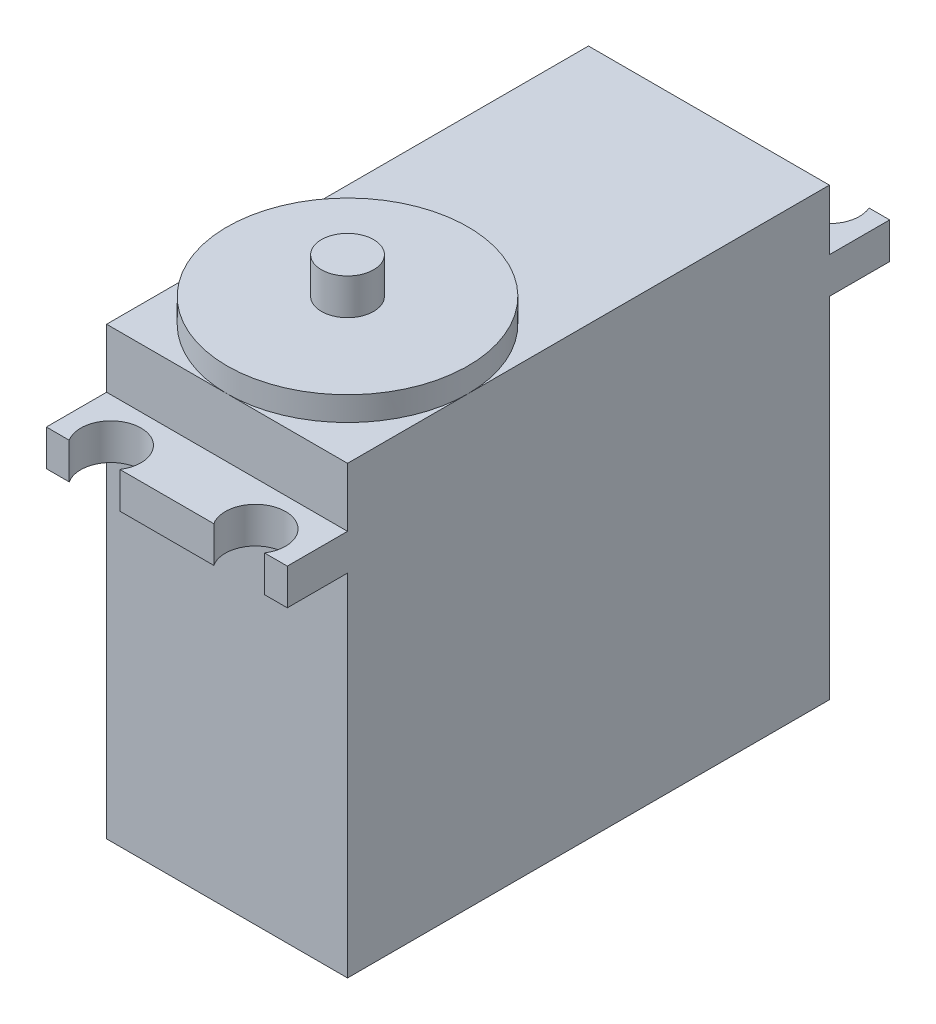
from build123d import *

# Parameters (mm, degrees)
SKETCH_1_W           = 20
SKETCH_1_H           = 40
EXTRUDE_1_DEPTH      = 37
SKETCH_2_R           = 0.75
CUT_EXTRUDE_10_DEPTH = 2
SKETCH_3_R           = 10
EXTRUDE_3_DEPTH      = 2
SKETCH_4_R           = 2.167388434
EXTRUDE_4_DEPTH      = 3
SKETCH_5_W           = 20
SKETCH_5_H           = 3
EXTRUDE_5_DEPTH      = 5
SKETCH_6_R           = 2.5
CUT_EXTRUDE_13_DEPTH = 3
SKETCH_9_W           = 20
SKETCH_9_H           = 3
EXTRUDE_7_DEPTH      = 5
SKETCH_10_R          = 2.5
CUT_EXTRUDE_14_DEPTH = 3


with BuildPart() as part:
    # 草图1 → 凸台-拉伸1 (new body)
    with BuildSketch(Plane(origin=(0, 0, 0), x_dir=(1, 0, 0), z_dir=(0, 1, 0))):
        Rectangle(SKETCH_1_W, SKETCH_1_H)
    extrude(amount=EXTRUDE_1_DEPTH)

    # 草图2 → 切除-拉伸10 (cut)
    with BuildSketch(Plane(origin=(0, 0, 0), x_dir=(1, 0, 0), z_dir=(0, 1, 0))):
        with Locations((-9, 19)):
            Circle(SKETCH_2_R)
        with Locations((9, 19)):
            Circle(SKETCH_2_R)
        with Locations((-9, -19)):
            Circle(SKETCH_2_R)
        with Locations((9, -19)):
            Circle(SKETCH_2_R)
    extrude(amount=CUT_EXTRUDE_10_DEPTH, mode=Mode.SUBTRACT)

    # 草图3 → 凸台-拉伸3 (add)
    with BuildSketch(Plane(origin=(0, 37, 0), x_dir=(1, 0, 0), z_dir=(0, 1, 0))):
        with Locations((0, -10)):
            Circle(SKETCH_3_R)
    extrude(amount=EXTRUDE_3_DEPTH)

    # 草图4 → 凸台-拉伸4 (add)
    with BuildSketch(Plane(origin=(0, 39, 0), x_dir=(1, 0, 0), z_dir=(0, 1, 0))):
        with Locations((0, -10)):
            Circle(SKETCH_4_R)
    extrude(amount=EXTRUDE_4_DEPTH)

    # 草图5 → 凸台-拉伸5 (add)
    with BuildSketch(Plane.XY.offset(20)):
        with Locations((0, 30.61035469)):
            Rectangle(SKETCH_5_W, SKETCH_5_H)
    extrude(amount=EXTRUDE_5_DEPTH)

    # 草图6 → 切除-拉伸13 (cut)
    with BuildSketch(Plane(origin=(0, 32.11035469, 0), x_dir=(1, 0, 0), z_dir=(0, 1, 0))):
        with Locations((-6, -23.644142826)):
            Circle(SKETCH_6_R)
        with Locations((6, -23.644142826)):
            Circle(SKETCH_6_R)
    extrude(amount=-CUT_EXTRUDE_13_DEPTH, mode=Mode.SUBTRACT)

    # 草图9 → 凸台-拉伸7 (add)
    with BuildSketch(Plane(origin=(0, 0, -20), x_dir=(-1, 0, 0), z_dir=(0, 0, -1))):
        with Locations((0, 30.5)):
            Rectangle(SKETCH_9_W, SKETCH_9_H)
    extrude(amount=EXTRUDE_7_DEPTH)

    # 草图10 → 切除-拉伸14 (cut)
    with BuildSketch(Plane(origin=(0, 32, 0), x_dir=(1, 0, 0), z_dir=(0, 1, 0))):
        with Locations((-6, 24)):
            Circle(SKETCH_10_R)
        with Locations((6, 24)):
            Circle(SKETCH_10_R)
    extrude(amount=-CUT_EXTRUDE_14_DEPTH, mode=Mode.SUBTRACT)


solid = part.part
